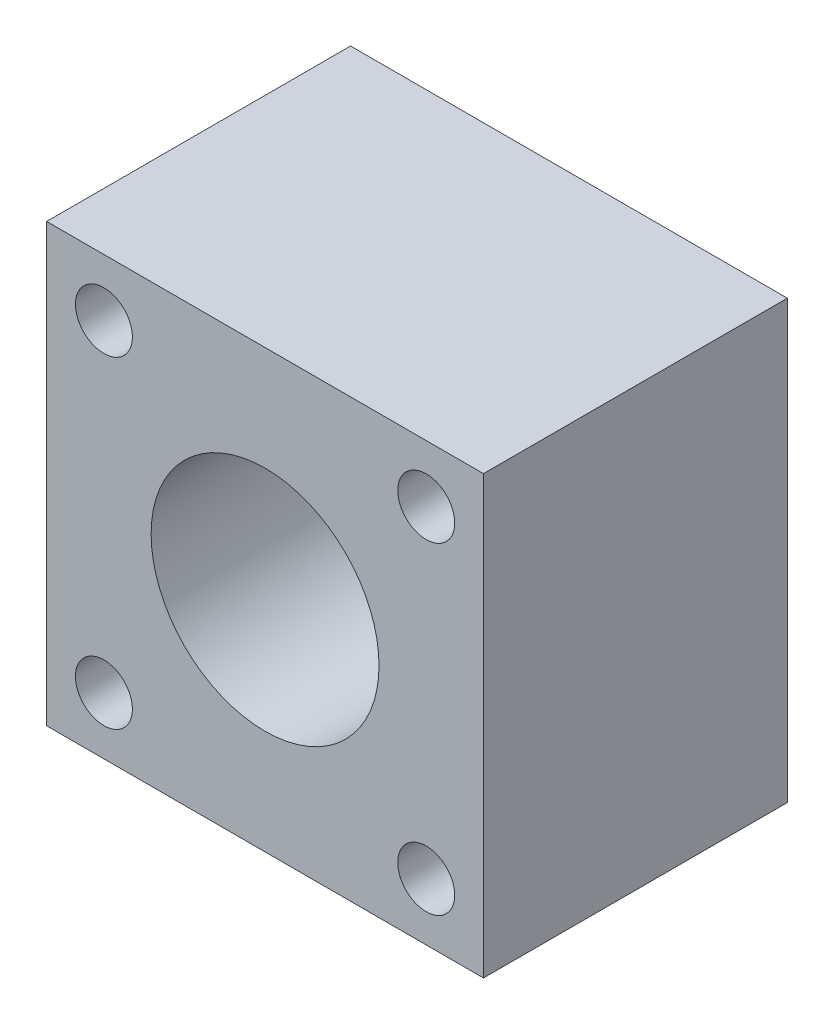
from build123d import *

# Parameters (mm, degrees)
SKETCH2_R           = 7.5
SKETCH2_R_2         = 6
EXTRUDE8_DEPTH      = 11
SKETCH2_14_W        = 23
SKETCH2_14_H        = 23
SKETCH2_14_R        = 7.5
SKETCH2_14_R_2      = 1.5
EXTRUDE9_DEPTH      = 11
EXTRUDE9_DEPTH_BACK = 5


with BuildPart() as part:
    # Sketch2 → Extrude8 (new body)
    with BuildSketch(Plane.XY):
        Circle(SKETCH2_R)
        Circle(SKETCH2_R_2, mode=Mode.SUBTRACT)
    extrude(amount=EXTRUDE8_DEPTH)

    # Sketch2_14 → Extrude9 (add, two sides)
    with BuildSketch(Plane.XY) as extrude9_sk:
        Rectangle(SKETCH2_14_W, SKETCH2_14_H)
        Circle(SKETCH2_14_R, mode=Mode.SUBTRACT)
        with Locations((8.485281374, 8.485281374)):
            Circle(SKETCH2_14_R_2, mode=Mode.SUBTRACT)
        with Locations((8.485281374, -8.485281374)):
            Circle(SKETCH2_14_R_2, mode=Mode.SUBTRACT)
        with Locations((-8.485281374, -8.485281374)):
            Circle(SKETCH2_14_R_2, mode=Mode.SUBTRACT)
        with Locations((-8.485281374, 8.485281374)):
            Circle(SKETCH2_14_R_2, mode=Mode.SUBTRACT)
    extrude(amount=EXTRUDE9_DEPTH)
    extrude(extrude9_sk.sketch, amount=-EXTRUDE9_DEPTH_BACK)


solid = part.part
